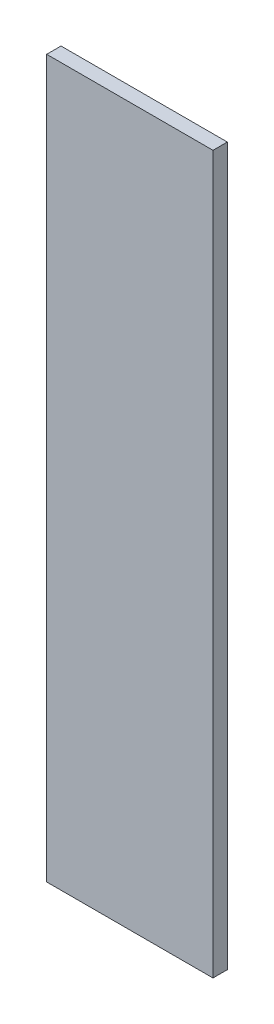
from build123d import *

# Parameters (mm, degrees)
ESQUISSE1_W        = 58
ESQUISSE1_H        = 250
BOSS_EXTRU_1_DEPTH = 5


with BuildPart() as part:
    # Esquisse1 → Boss.-Extru.1 (new body)
    with BuildSketch(Plane.XY):
        with Locations((29, 125)):
            Rectangle(ESQUISSE1_W, ESQUISSE1_H)
    extrude(amount=BOSS_EXTRU_1_DEPTH)


solid = part.part
